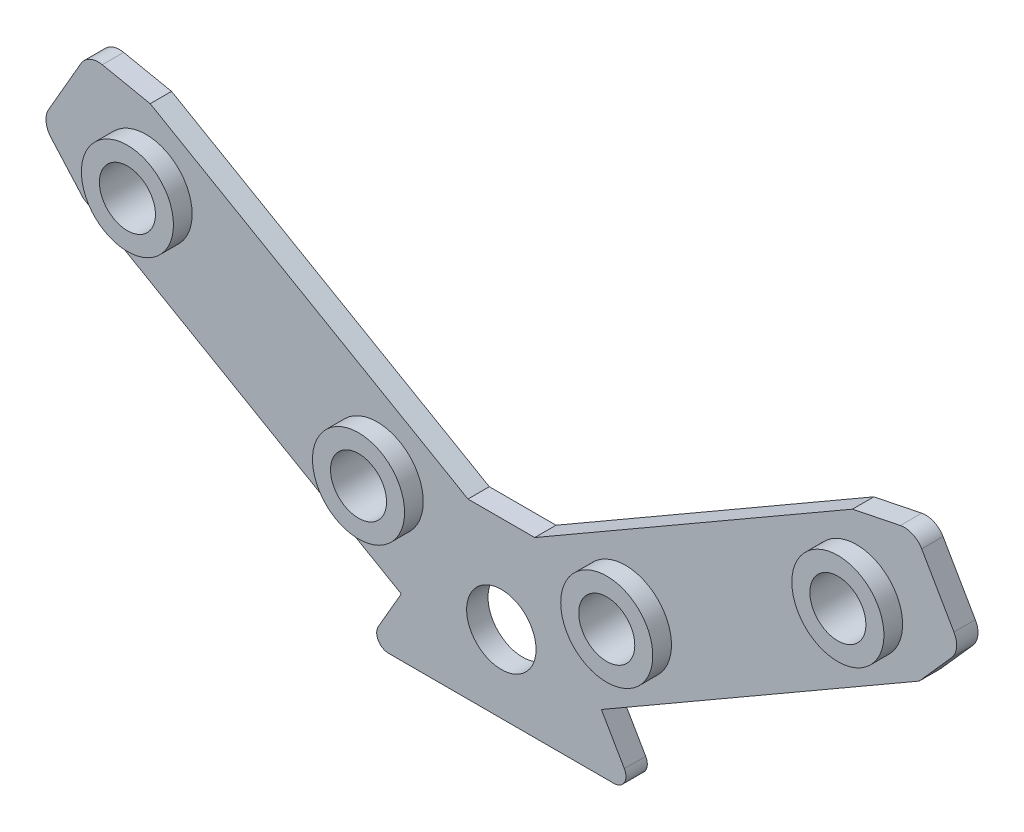
from build123d import *

# Parameters (mm, degrees)
SKETCH1_R             = 2.6
BOSS_EXTRUDE1_DEPTH   = 1.6
SKETCH2_R             = 3.45
BOSS_EXTRUDE2_DEPTH   = 1.4
M5X0_8_TAPPED_HOLE1_D = 4.2


with BuildPart() as part:
    # Sketch1 → Boss-Extrude1 (new body)
    with BuildSketch(Plane.XY):
        with BuildLine():
            Line((-2.5, 7.216878365), (2.5, 7.216878365))
            Line((2.5, 7.216878365), (26.315698604, 20.966878365))
            Line((26.315698604, 20.966878365), (29.903623675, 21.701093146))
            ThreePointArc((29.903623675, 21.701093146), (30.819646028, 21.599539147), (31.503382336, 20.981546567))
            Line((31.503382336, 20.981546567), (33.922243506, 16.791956125))
            ThreePointArc((33.922243506, 16.791956125), (34.115572625, 15.890826823), (33.745509792, 15.046751195))
            Line((33.745509792, 15.046751195), (31.315698604, 12.306624327))
            Line((31.315698604, 12.306624327), (7.5, -1.443375673))
            Line((7.5, -1.443375673), (9.220577137, -4.423502692))
            ThreePointArc((9.220577137, -4.423502692), (9.220577137, -5.323502692), (8.441154273, -5.773502692))
            Line((8.441154273, -5.773502692), (-8.441154273, -5.773502692))
            ThreePointArc((-8.441154273, -5.773502692), (-9.220577137, -5.323502692), (-9.220577137, -4.423502692))
            Line((-9.220577137, -4.423502692), (-7.5, -1.443375673))
            Line((-7.5, -1.443375673), (-31.315698604, 12.306624327))
            Line((-31.315698604, 12.306624327), (-33.745509792, 15.046751195))
            ThreePointArc((-33.745509792, 15.046751195), (-34.115572625, 15.890826823), (-33.922243506, 16.791956125))
            Line((-33.922243506, 16.791956125), (-31.503382336, 20.981546567))
            ThreePointArc((-31.503382336, 20.981546567), (-30.819646028, 21.599539147), (-29.903623675, 21.701093146))
            Line((-29.903623675, 21.701093146), (-26.315698604, 20.966878365))
            Line((-26.315698604, 20.966878365), (-2.5, 7.216878365))
        make_face()
        Circle(SKETCH1_R, mode=Mode.SUBTRACT)
    extrude(amount=BOSS_EXTRUDE1_DEPTH)

    # Sketch2 → Boss-Extrude2 (add)
    with BuildSketch(Plane.XY.offset(1.6)):
        with Locations((26.621620912, 15.37)):
            Circle(SKETCH2_R)
        with Locations((9.301112837, 5.37)):
            Circle(SKETCH2_R)
        with Locations((-9.301112837, 5.37)):
            Circle(SKETCH2_R)
        with Locations((-26.621620912, 15.37)):
            Circle(SKETCH2_R)
    extrude(amount=BOSS_EXTRUDE2_DEPTH)

    # M5x0.8 Tapped Hole1 (through all)
    with Locations(Plane.XY.offset(3)):
        with Locations((26.621620912, 15.37), (9.301112837, 5.37), (-9.301112837, 5.37), (-26.621620912, 15.37)):
            Hole(M5X0_8_TAPPED_HOLE1_D / 2)


solid = part.part
